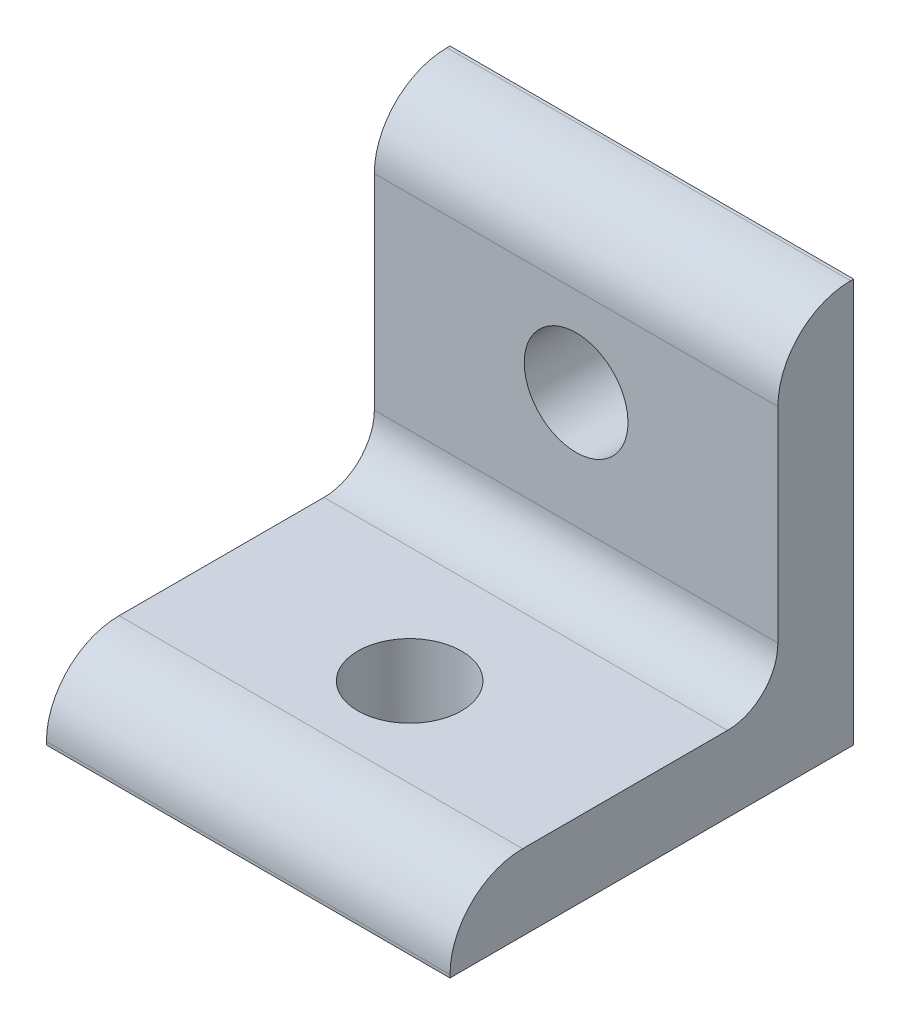
from build123d import *

# Parameters (mm, degrees)
BOSS_EXTRUDE1_DEPTH     = 25.4
F_1_4_CLEARANCE_HOLE1_D = 6.5278
F_1_4_CLEARANCE_HOLE2_D = 6.5278


with BuildPart() as part:
    # Sketch1 → Boss-Extrude1 (new body)
    with BuildSketch(Plane(origin=(0, -22.225, 0), x_dir=(0, -1, 0), z_dir=(-1, 0, 0))):
        with BuildLine():
            Line((-22.225, 0), (-22.225, 25.4))
            Line((-22.225, 25.4), (-22.4155, 25.4))
            ThreePointArc((-22.4155, 25.4), (-25.648392204, 24.060892204), (-26.9875, 20.828))
            Line((-26.9875, 20.828), (-26.9875, 7.9375))
            ThreePointArc((-26.9875, 7.9375), (-27.91743597, 5.69243597), (-30.1625, 4.7625))
            Line((-30.1625, 4.7625), (-43.053, 4.7625))
            ThreePointArc((-43.053, 4.7625), (-46.285892204, 3.423392204), (-47.625, 0.1905))
            Line((-47.625, 0.1905), (-47.625, 0))
            Line((-47.625, 0), (-22.225, 0))
        make_face()
    extrude(amount=-BOSS_EXTRUDE1_DEPTH)

    # 1/4 Clearance Hole1 (through all)
    with Locations(Plane(origin=(0, 0, 0), x_dir=(-1, 0, 0), z_dir=(0, 0, -1))):
        with Locations((-12.7, 15.24)):
            Hole(F_1_4_CLEARANCE_HOLE1_D / 2)

    # 1/4 Clearance Hole2 (through all)
    with Locations(Plane(origin=(0, 0, 0), x_dir=(-1, 0, 0), z_dir=(0, -1, 0))):
        with Locations((-12.7, -15.24)):
            Hole(F_1_4_CLEARANCE_HOLE2_D / 2)


solid = part.part
